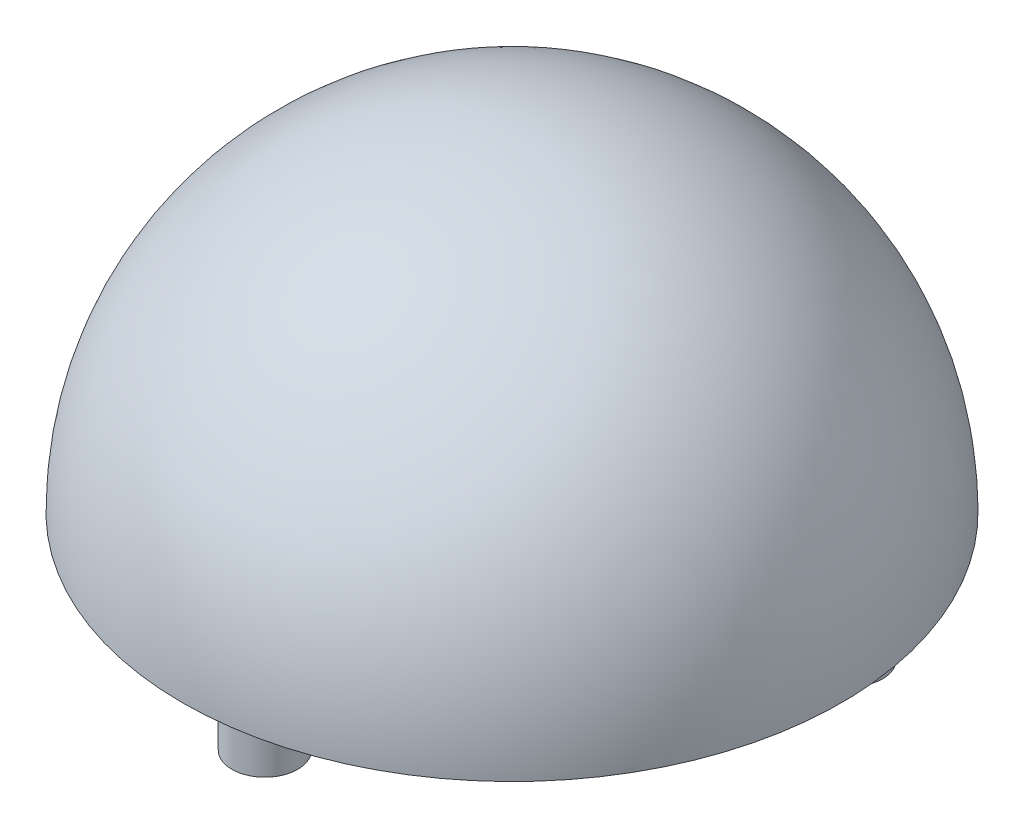
from build123d import *

# Parameters (mm, degrees)
REVOLVE1_ANGLE      = 180
CUT_REVOLVE1_ANGLE  = 180
SKETCH4_R           = 39
BOSS_EXTRUDE2_DEPTH = 4
SKETCH2_R           = 4
SKETCH2_R_2         = 1.5
BOSS_EXTRUDE3_DEPTH = 10
SKETCH5_R           = 22.5
CUT_EXTRUDE1_DEPTH  = 5
SKETCH6_W           = 6
SKETCH6_H           = 6
BOSS_EXTRUDE4_DEPTH = 5
SKETCH7_R           = 7
BOSS_EXTRUDE5_DEPTH = 5
SKETCH8_W           = 2
SKETCH8_H           = 2
BOSS_EXTRUDE6_DEPTH = 10


with BuildPart() as part:
    # Sketch1 → Revolve1 (revolve)
    with BuildSketch(Plane(origin=(0, 0, 0), x_dir=(1, 0, 0), z_dir=(0, 1, 0))):
        with BuildLine():
            Line((-40, 0), (40, 0))
            ThreePointArc((40, 0), (0, 40), (-40, 0))
        make_face()
    revolve(axis=Axis((-40, 0, 0), (1, 0, 0)), revolution_arc=REVOLVE1_ANGLE)

    # Sketch3 → Cut-Revolve1 (revolve, cut)
    with BuildSketch(Plane.XZ):
        with BuildLine():
            Line((0, 36), (0, -36))
            ThreePointArc((0, -36), (36, 0), (0, 36))
        make_face()
    revolve(axis=Axis((0, 0, 36), (0, 0, 1)), revolution_arc=CUT_REVOLVE1_ANGLE, mode=Mode.SUBTRACT)

    # Sketch4 → Boss-Extrude2 (add)
    with BuildSketch(Plane.XZ):
        Circle(SKETCH4_R)
    extrude(amount=-BOSS_EXTRUDE2_DEPTH)

    # Sketch2 → Boss-Extrude3 (add)
    with BuildSketch(Plane(origin=(0, 0, 0), x_dir=(-1, 0, 0), z_dir=(0, -1, 0))):
        with Locations((0, -30)):
            Circle(SKETCH2_R)
        with Locations((0, -30)):
            Circle(SKETCH2_R_2, mode=Mode.SUBTRACT)
        with Locations((25.980762114, 15)):
            Circle(SKETCH2_R)
        with Locations((25.980762114, 15)):
            Circle(SKETCH2_R_2, mode=Mode.SUBTRACT)
        with Locations((-25.980762114, 15)):
            Circle(SKETCH2_R)
        with Locations((-25.980762114, 15)):
            Circle(SKETCH2_R_2, mode=Mode.SUBTRACT)
    extrude(amount=BOSS_EXTRUDE3_DEPTH)

    # Sketch5 → Cut-Extrude1 (cut)
    with BuildSketch(Plane.XZ):
        Circle(SKETCH5_R)
    extrude(amount=-CUT_EXTRUDE1_DEPTH, mode=Mode.SUBTRACT)

    # Sketch6 → Boss-Extrude4 (add)
    with BuildSketch(Plane.XZ):
        with BuildLine():
            ThreePointArc((-22.299103121, -3), (-22.5, 0), (-22.299103121, 3))
            Line((-22.299103121, 3), (-27, 3))
            Line((-27, 3), (-27, -3))
            Line((-27, -3), (-22.299103121, -3))
        make_face()
        with BuildLine():
            Line((-3, -3), (-3, 3))
            Line((-3, 3), (-22.299103121, 3))
            ThreePointArc((-22.299103121, 3), (-22.5, 0), (-22.299103121, -3))
            Line((-22.299103121, -3), (-3, -3))
        make_face()
        Rectangle(SKETCH6_W, SKETCH6_H)
        with BuildLine():
            Line((22.299103121, 3), (3, 3))
            Line((3, 3), (3, -3))
            Line((3, -3), (22.299103121, -3))
            ThreePointArc((22.299103121, -3), (22.4497196, -1.503359534), (22.5, 0))
            ThreePointArc((22.5, 0), (22.4497196, 1.503359534), (22.299103121, 3))
        make_face()
        with BuildLine():
            Line((27, 3), (22.299103121, 3))
            ThreePointArc((22.299103121, 3), (22.4497196, 1.503359534), (22.5, 0))
            ThreePointArc((22.5, 0), (22.4497196, -1.503359534), (22.299103121, -3))
            Line((22.299103121, -3), (27, -3))
            Line((27, -3), (27, 3))
        make_face()
        with BuildLine():
            ThreePointArc((3, 22.299103121), (0, 22.5), (-3, 22.299103121))
            Line((-3, 22.299103121), (-3, 3))
            Line((-3, 3), (3, 3))
            Line((3, 3), (3, 22.299103121))
        make_face()
        with BuildLine():
            Line((3, 25), (-3, 25))
            Line((-3, 25), (-3, 22.299103121))
            ThreePointArc((-3, 22.299103121), (0, 22.5), (3, 22.299103121))
            Line((3, 22.299103121), (3, 25))
        make_face()
        with BuildLine():
            Line((3, -3), (-3, -3))
            Line((-3, -3), (-3, -22.299103121))
            ThreePointArc((-3, -22.299103121), (0, -22.5), (3, -22.299103121))
            Line((3, -22.299103121), (3, -3))
        make_face()
        with BuildLine():
            ThreePointArc((3, -22.299103121), (0, -22.5), (-3, -22.299103121))
            Line((-3, -22.299103121), (-3, -27))
            Line((-3, -27), (3, -27))
            Line((3, -27), (3, -22.299103121))
        make_face()
    extrude(amount=-BOSS_EXTRUDE4_DEPTH)

    # Sketch7 → Boss-Extrude5 (add)
    with BuildSketch(Plane.XZ):
        Circle(SKETCH7_R)
    extrude(amount=-BOSS_EXTRUDE5_DEPTH)

    # Sketch8 → Boss-Extrude6 (add)
    with BuildSketch(Plane.XZ):
        with BuildLine():
            ThreePointArc((-2.828427125, -1), (-3, 0), (-2.828427125, 1))
            Line((-2.828427125, 1), (-4.3, 1))
            Line((-4.3, 1), (-4.3, -1))
            Line((-4.3, -1), (-2.828427125, -1))
        make_face()
        with BuildLine():
            Line((1, 4.3), (-1, 4.3))
            Line((-1, 4.3), (-1, 2.828427125))
            ThreePointArc((-1, 2.828427125), (0, 3), (1, 2.828427125))
            Line((1, 2.828427125), (1, 4.3))
        make_face()
        with BuildLine():
            Line((-1, 1), (-1, 2.828427125))
            ThreePointArc((-1, 2.828427125), (-2.121320344, 2.121320344), (-2.828427125, 1))
            Line((-2.828427125, 1), (-1, 1))
        make_face()
        with BuildLine():
            ThreePointArc((1, 2.828427125), (0, 3), (-1, 2.828427125))
            Line((-1, 2.828427125), (-1, 1))
            Line((-1, 1), (1, 1))
            Line((1, 1), (1, 2.828427125))
        make_face()
        with BuildLine():
            ThreePointArc((2.828427125, 1), (2.121320344, 2.121320344), (1, 2.828427125))
            Line((1, 2.828427125), (1, 1))
            Line((1, 1), (2.828427125, 1))
        make_face()
        with BuildLine():
            Line((2.828427125, 1), (1, 1))
            Line((1, 1), (1, -1))
            Line((1, -1), (2.828427125, -1))
            ThreePointArc((2.828427125, -1), (2.956795679, -0.507305936), (3, 0))
            ThreePointArc((3, 0), (2.956795679, 0.507305936), (2.828427125, 1))
        make_face()
        with BuildLine():
            Line((4.3, 1), (2.828427125, 1))
            ThreePointArc((2.828427125, 1), (2.956795679, 0.507305936), (3, 0))
            ThreePointArc((3, 0), (2.956795679, -0.507305936), (2.828427125, -1))
            Line((2.828427125, -1), (4.3, -1))
            Line((4.3, -1), (4.3, 1))
        make_face()
        Rectangle(SKETCH8_W, SKETCH8_H)
        with BuildLine():
            Line((-1, -1), (-1, 1))
            Line((-1, 1), (-2.828427125, 1))
            ThreePointArc((-2.828427125, 1), (-3, 0), (-2.828427125, -1))
            Line((-2.828427125, -1), (-1, -1))
        make_face()
        with BuildLine():
            Line((2.828427125, -1), (1, -1))
            Line((1, -1), (1, -2.828427125))
            ThreePointArc((1, -2.828427125), (2.121320344, -2.121320344), (2.828427125, -1))
        make_face()
        with BuildLine():
            Line((-1, -2.828427125), (-1, -1))
            Line((-1, -1), (-2.828427125, -1))
            ThreePointArc((-2.828427125, -1), (-2.121320344, -2.121320344), (-1, -2.828427125))
        make_face()
        with BuildLine():
            Line((1, -1), (-1, -1))
            Line((-1, -1), (-1, -2.828427125))
            ThreePointArc((-1, -2.828427125), (0, -3), (1, -2.828427125))
            Line((1, -2.828427125), (1, -1))
        make_face()
        with BuildLine():
            ThreePointArc((1, -2.828427125), (0, -3), (-1, -2.828427125))
            Line((-1, -2.828427125), (-1, -4.3))
            Line((-1, -4.3), (1, -4.3))
            Line((1, -4.3), (1, -2.828427125))
        make_face()
    extrude(amount=BOSS_EXTRUDE6_DEPTH)


solid = part.part
